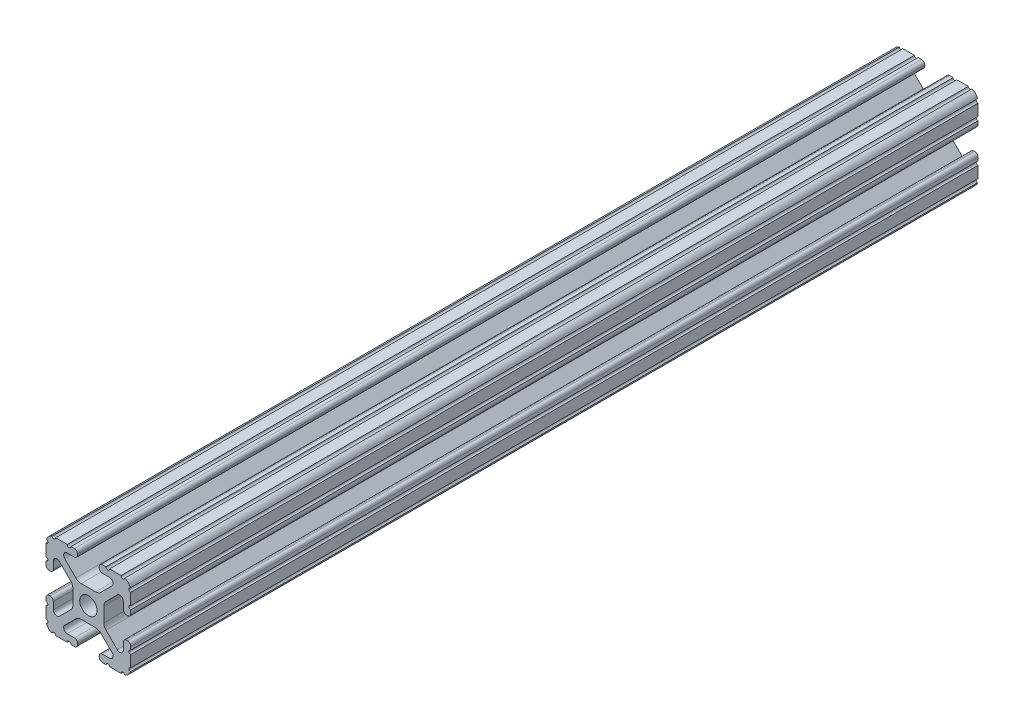
from build123d import *

# Parameters (mm, degrees)
BOSS_EXTRUDE1_DEPTH     = 127
SKETCH5_R               = 0.55245
CUT_EXTRUDE1_DEPTH      = 128
CUT_EXTRUDE1_DEPTH_BACK = 128


with BuildPart() as part:
    # Sketch4 → Boss-Extrude1 (new body, symmetric)
    with BuildSketch(Plane.XY):
        with BuildLine():
            Line((4.190365, -12.7), (10.11729625, -12.7))
            ThreePointArc((10.11729625, -12.7), (11.943543585, -11.943543585), (12.7, -10.11729625))
            Line((12.7, -10.11729625), (12.7, -4.190365))
            ThreePointArc((12.7, -4.190365), (12.42492494, -3.52627506), (11.760835, -3.2512))
            Line((11.760835, -3.2512), (11.429365, -3.2512))
            ThreePointArc((11.429365, -3.2512), (10.76527506, -3.52627506), (10.4902, -4.190365))
            Line((10.4902, -4.190365), (10.4902, -6.348478019))
            ThreePointArc((10.4902, -6.348478019), (9.830707141, -7.335478831), (8.666460301, -7.103895736))
            Line((8.666460301, -7.103895736), (5.299899128, -3.737334563))
            ThreePointArc((5.299899128, -3.737334563), (4.817571085, -3.015479634), (4.6482, -2.16399369))
            Line((4.6482, -2.16399369), (4.6482, 0))
            Line((4.6482, 0), (2.6035, 0))
            ThreePointArc((2.6035, 0), (1.840952505, -1.840952505), (0, -2.6035))
            Line((0, -2.6035), (0, -4.6482))
            Line((0, -4.6482), (2.16399369, -4.6482))
            ThreePointArc((2.16399369, -4.6482), (3.015479634, -4.817571085), (3.737334563, -5.299899128))
            Line((3.737334563, -5.299899128), (7.103895736, -8.666460301))
            ThreePointArc((7.103895736, -8.666460301), (7.335478831, -9.830707141), (6.348478019, -10.4902))
            Line((6.348478019, -10.4902), (4.190365, -10.4902))
            ThreePointArc((4.190365, -10.4902), (3.52627506, -10.76527506), (3.2512, -11.429365))
            Line((3.2512, -11.429365), (3.2512, -11.760835))
            ThreePointArc((3.2512, -11.760835), (3.52627506, -12.42492494), (4.190365, -12.7))
        make_face()
    extrude(amount=BOSS_EXTRUDE1_DEPTH, both=True)

    # Sketch5 → Cut-Extrude1 (cut, two sides)
    with BuildSketch(Plane.XY) as cut_extrude1_sk:
        with Locations((10.356153152, -12.7)):
            Circle(SKETCH5_R)
        with Locations((5.796028019, -12.7)):
            Circle(SKETCH5_R)
        with Locations((12.7, -10.356153152)):
            Circle(SKETCH5_R)
        with Locations((12.7, -5.796028019)):
            Circle(SKETCH5_R)
    extrude(amount=CUT_EXTRUDE1_DEPTH, mode=Mode.SUBTRACT)
    extrude(cut_extrude1_sk.sketch, amount=-CUT_EXTRUDE1_DEPTH_BACK, mode=Mode.SUBTRACT)

    # Mirror1: part across plane


with BuildPart() as part_1:
    add(part.part)
    add(part.part.mirror(Plane(origin=(0, 0, 0), x_dir=(0, 0, 1), z_dir=(1, 0, 0))))

    # Mirror2: part across plane


with BuildPart() as part_2:
    add(part_1.part)
    add(part_1.part.mirror(Plane.ZX))


solid = part_2.part
